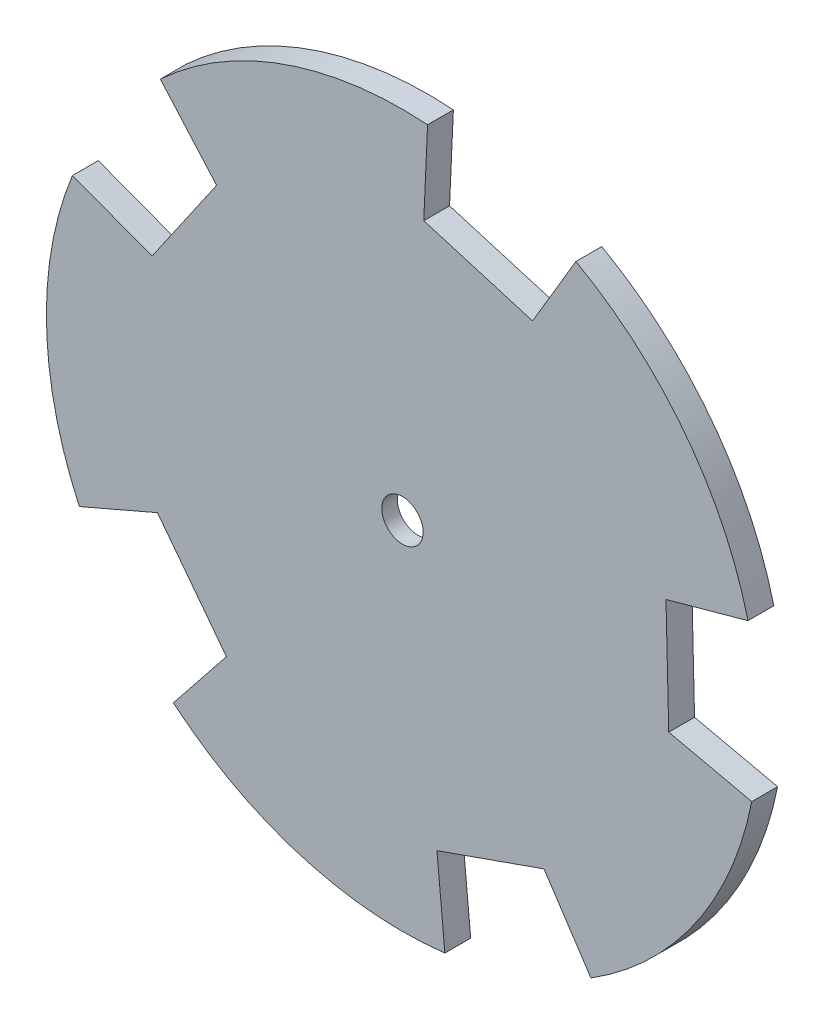
from build123d import *

# Parameters (mm, degrees)
BOSS_EXTRUDE1_DEPTH = 1.5
SKETCH2_R           = 4.075
BOSS_EXTRUDE2_DEPTH = 1
SKETCH3_R           = 2
CUT_EXTRUDE1_DEPTH  = 2.5


with BuildPart() as part:
    # Sketch1 → Boss-Extrude1 (new body)
    with BuildSketch(Plane.XY):
        with BuildLine():
            Line((-23.460220375, 25.295613453), (-18.010816917, 19.106590755))
            Line((-18.010816917, 19.106590755), (-24.257098112, 10.052090702))
            Line((-24.257098112, 10.052090702), (-31.977876551, 12.948567925))
            ThreePointArc((-31.977876551, 12.948567925), (-34.489701397, -0.842910146), (-31.307164796, -14.495221021))
            Line((-31.307164796, -14.495221021), (-23.737096152, -11.225043545))
            Line((-23.737096152, -11.225043545), (-17.055961915, -19.96360437))
            Line((-17.055961915, -19.96360437), (-22.1965272, -26.411440329))
            ThreePointArc((-22.1965272, -26.411440329), (-9.856248675, -33.062128819), (4.11132844, -34.254152718))
            Line((4.11132844, -34.254152718), (3.340484701, -26.044049191))
            Line((3.340484701, -26.044049191), (13.715933938, -22.39027674))
            Line((13.715933938, -22.39027674), (18.259668309, -29.27173574))
            ThreePointArc((18.259668309, -29.27173574), (28.398204714, -19.590609204), (33.84810551, -6.675009615))
            Line((33.84810551, -6.675009615), (25.801629236, -4.87106406))
            Line((25.801629236, -4.87106406), (25.532875276, 6.125652327))
            Line((25.532875276, 6.125652327), (33.481622838, 8.320512732))
            ThreePointArc((33.481622838, 8.320512732), (27.407304408, 20.95446647), (16.80795122, 30.128769901))
            Line((16.80795122, 30.128769901), (12.605799132, 23.03356604))
            Line((12.605799132, 23.03356604), (2.064250813, 26.176138082))
            Line((2.064250813, 26.176138082), (2.433112603, 34.414095412))
            ThreePointArc((2.433112603, 34.414095412), (-11.45955905, 32.541181699), (-23.460220375, 25.295613453))
        make_face()
    extrude(amount=BOSS_EXTRUDE1_DEPTH)

    # Sketch2 → Boss-Extrude2 (add)
    with BuildSketch(Plane(origin=(0, 0, 0), x_dir=(-1, 0, 0), z_dir=(0, 0, -1))):
        with BuildLine():
            Line((-2.433112603, 34.414095412), (-2.064250813, 26.176138082))
            Line((-2.064250813, 26.176138082), (-12.605799132, 23.03356604))
            Line((-12.605799132, 23.03356604), (-16.80795122, 30.128769901))
            ThreePointArc((-16.80795122, 30.128769901), (-27.407304408, 20.95446647), (-33.481622838, 8.320512732))
            Line((-33.481622838, 8.320512732), (-25.532875276, 6.125652327))
            Line((-25.532875276, 6.125652327), (-25.801629236, -4.87106406))
            Line((-25.801629236, -4.87106406), (-33.84810551, -6.675009615))
            ThreePointArc((-33.84810551, -6.675009615), (-28.398204714, -19.590609204), (-18.259668309, -29.27173574))
            Line((-18.259668309, -29.27173574), (-13.715933938, -22.39027674))
            Line((-13.715933938, -22.39027674), (-3.340484701, -26.044049191))
            Line((-3.340484701, -26.044049191), (-4.11132844, -34.254152718))
            ThreePointArc((-4.11132844, -34.254152718), (9.856248675, -33.062128819), (22.1965272, -26.411440329))
            Line((22.1965272, -26.411440329), (17.055961915, -19.96360437))
            Line((17.055961915, -19.96360437), (23.737096152, -11.225043545))
            Line((23.737096152, -11.225043545), (31.307164796, -14.495221021))
            ThreePointArc((31.307164796, -14.495221021), (34.489701397, -0.842910146), (31.977876551, 12.948567925))
            Line((31.977876551, 12.948567925), (24.257098112, 10.052090702))
            Line((24.257098112, 10.052090702), (18.010816917, 19.106590755))
            Line((18.010816917, 19.106590755), (23.460220375, 25.295613453))
            ThreePointArc((23.460220375, 25.295613453), (11.45955905, 32.541181699), (-2.433112603, 34.414095412))
        make_face()
        Circle(SKETCH2_R, mode=Mode.SUBTRACT)
    extrude(amount=BOSS_EXTRUDE2_DEPTH)

    # Sketch3 → Cut-Extrude1 (cut, through all)
    with BuildSketch(Plane(origin=(0, 0, 0), x_dir=(-1, 0, 0), z_dir=(0, 0, -1))):
        Circle(SKETCH3_R)
    extrude(amount=-CUT_EXTRUDE1_DEPTH, mode=Mode.SUBTRACT)


solid = part.part
